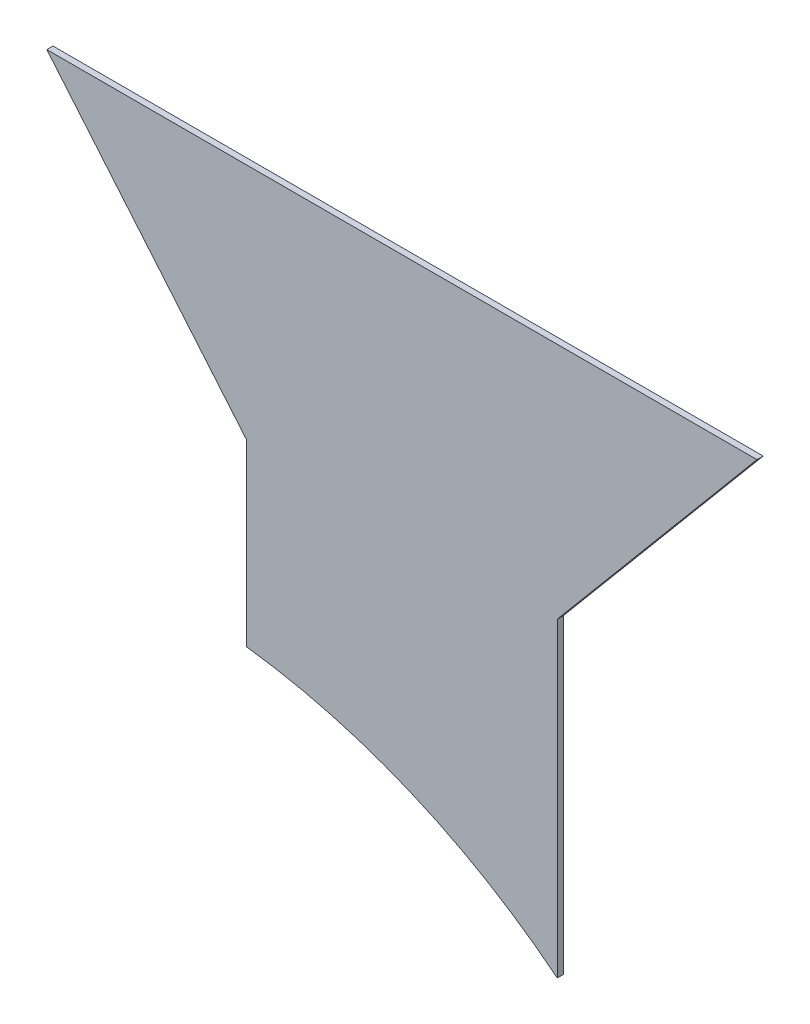
from build123d import *

# Parameters (mm, degrees)
FUNNEL_SIDE_PANEL_DEPTH = 1.51892


with BuildPart() as part:
    # Sketch1 → Funnel - Side Panel (new body)
    with BuildSketch(Plane.XY):
        with BuildLine():
            Line((38.1, 0), (38.1, 76.2))
            Line((38.1, 76.2), (87.080415858, 134.572586566))
            Line((87.080415858, 134.572586566), (-87.080415858, 134.572586566))
            Line((-87.080415858, 134.572586566), (-38.1, 76.2))
            Line((-38.1, 76.2), (-38.1, 32.237475558))
            ThreePointArc((-38.1, 32.237475558), (2.229594202, 21.388848892), (38.1, 0))
        make_face()
    extrude(amount=FUNNEL_SIDE_PANEL_DEPTH)


solid = part.part
